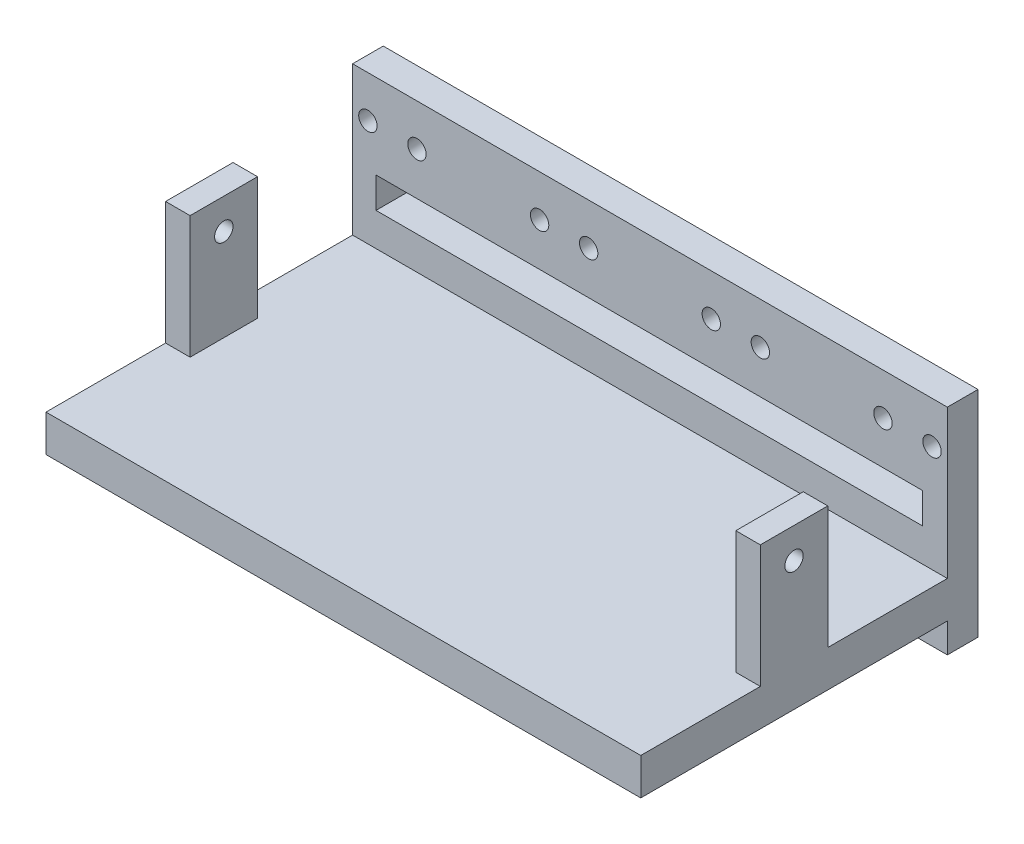
from build123d import *

# Parameters (mm, degrees)
SKETCH1_W                      = 97
SKETCH1_H                      = 30
SKETCH1_R                      = 1.5
BOSS_EXTRUDE1_DEPTH            = 5
SKETCH2_W                      = 20.6
SKETCH2_H                      = 5
BOSS_EXTRUDE2_DEPTH            = 10
CUT_EXTRUDE1_REACH             = 99
CUT_EXTRUDE1_DIRECTION_2_DEPTH = 1
BOSS_EXTRUDE3_DEPTH            = 20.6
SKETCH5_W                      = 12
SKETCH5_H                      = 3.995489472
BOSS_EXTRUDE4_DEPTH            = 4.086588
SKETCH6_R                      = 1.6
CUT_EXTRUDE3_DEPTH             = 2
SKETCH7_W                      = 97
SKETCH7_H                      = 5
BOSS_EXTRUDE5_DEPTH            = 5
SKETCH8_W                      = 89.150949319
SKETCH8_H                      = 5
CUT_EXTRUDE5_DEPTH             = 6
SKETCH10_W                     = 97
SKETCH10_H                     = 6
BOSS_EXTRUDE7_DEPTH            = 50
SKETCH11_W                     = 4
SKETCH11_H                     = 11
BOSS_EXTRUDE8_DEPTH            = 20
SKETCH12_R                     = 1.5
CUT_EXTRUDE6_DEPTH             = 98


with BuildPart() as part:
    # Sketch1 → Boss-Extrude1 (new body)
    with BuildSketch(Plane.XY):
        Rectangle(SKETCH1_W, SKETCH1_H)
        with Locations((-46, 13.2)):
            Circle(SKETCH1_R, mode=Mode.SUBTRACT)
        with Locations((-38, 13.2)):
            Circle(SKETCH1_R, mode=Mode.SUBTRACT)
        with Locations((-18, 13.2)):
            Circle(SKETCH1_R, mode=Mode.SUBTRACT)
        with Locations((-10, 13.2)):
            Circle(SKETCH1_R, mode=Mode.SUBTRACT)
        with Locations((10, 13.2)):
            Circle(SKETCH1_R, mode=Mode.SUBTRACT)
        with Locations((18, 13.2)):
            Circle(SKETCH1_R, mode=Mode.SUBTRACT)
        with Locations((38, 13.2)):
            Circle(SKETCH1_R, mode=Mode.SUBTRACT)
        with Locations((46, 13.2)):
            Circle(SKETCH1_R, mode=Mode.SUBTRACT)
    extrude(amount=-BOSS_EXTRUDE1_DEPTH)

    # Sketch2 → Boss-Extrude2 (add)
    with BuildSketch(Plane.XZ.offset(15)):
        with Locations((-38.2, -2.5)):
            Rectangle(SKETCH2_W, SKETCH2_H)
    extrude(amount=BOSS_EXTRUDE2_DEPTH)

    # Sketch3 → Cut-Extrude1 (cut, up to next)
    with BuildSketch(Plane.ZY.offset(48.5), mode=Mode.PRIVATE) as cut_extrude1_sk1:
        Polygon((0, -25), (-5, -25), (0, -23.785067119), align=None)
    cut_extrude1_tool1 = extrude(cut_extrude1_sk1.sketch, amount=-CUT_EXTRUDE1_REACH, mode=Mode.PRIVATE) & part.part
    add(cut_extrude1_tool1.solids().sort_by_distance((-48.5, -24.595022, -1.666667))[0], mode=Mode.SUBTRACT)

    # Sketch3 → Cut-Extrude1 direction 2 (cut)
    with BuildSketch(Plane.ZY.offset(48.5)):
        Polygon((0, -25), (-5, -25), (0, -23.785067119), align=None)
    extrude(amount=CUT_EXTRUDE1_DIRECTION_2_DEPTH, mode=Mode.SUBTRACT)

    # Sketch4 → Boss-Extrude3 (add)
    with BuildSketch(Plane.ZY.offset(48.5)):
        Polygon((0, -23.785067119), (-1.117483581, -24.056600628), (-0.16158282, -27.990565936), align=None)
    extrude(amount=-BOSS_EXTRUDE3_DEPTH)

    # Sketch5 → Boss-Extrude4 (add)
    with BuildSketch(Plane(origin=(0, -22.459030354, 5.45724289), x_dir=(1, 0, 0), z_dir=(0, -0.971724853, 0.236116095))):
        with Locations((-38.9, -8.763781903)):
            Rectangle(SKETCH5_W, SKETCH5_H)
    extrude(amount=BOSS_EXTRUDE4_DEPTH)

    # Sketch6 → Cut-Extrude3 (cut)
    with BuildSketch(Plane(origin=(0, -1.597570275, -6.574726471), x_dir=(-1, 0, 0), z_dir=(0, -0.236116095, -0.971724853))):
        with Locations((46.634175133, -25.412540847)):
            Circle(SKETCH6_R)
    extrude(amount=-CUT_EXTRUDE3_DEPTH, mode=Mode.SUBTRACT)

    # Sketch7 → Boss-Extrude5 (add, through all)
    with BuildSketch(Plane.XY):
        with Locations((0, 17.5)):
            Rectangle(SKETCH7_W, SKETCH7_H)
    extrude(amount=-BOSS_EXTRUDE5_DEPTH)

    # Sketch8 → Cut-Extrude5 (cut, through all)
    with BuildSketch(Plane.XY):
        with Locations((-0.104637264, 3.7)):
            Rectangle(SKETCH8_W, SKETCH8_H)
    extrude(amount=-CUT_EXTRUDE5_DEPTH, mode=Mode.SUBTRACT)

    # Sketch10 → Boss-Extrude7 (add)
    with BuildSketch(Plane.XY):
        with Locations((0, -7.199863622)):
            Rectangle(SKETCH10_W, SKETCH10_H)
    extrude(amount=BOSS_EXTRUDE7_DEPTH)

    # Sketch11 → Boss-Extrude8 (add)
    with BuildSketch(Plane(origin=(0, -4.199863622, 0), x_dir=(1, 0, 0), z_dir=(0, 1, 0))):
        with Locations((46.5, -25)):
            Rectangle(SKETCH11_W, SKETCH11_H)
        with Locations((-46.5, -25)):
            Rectangle(SKETCH11_W, SKETCH11_H)
    extrude(amount=BOSS_EXTRUDE8_DEPTH)

    # Sketch12 → Cut-Extrude6 (cut, through all)
    with BuildSketch(Plane.ZY.offset(48.5)):
        with Locations((25, 10.800136378)):
            Circle(SKETCH12_R)
    extrude(amount=-CUT_EXTRUDE6_DEPTH, mode=Mode.SUBTRACT)


solid = part.part
